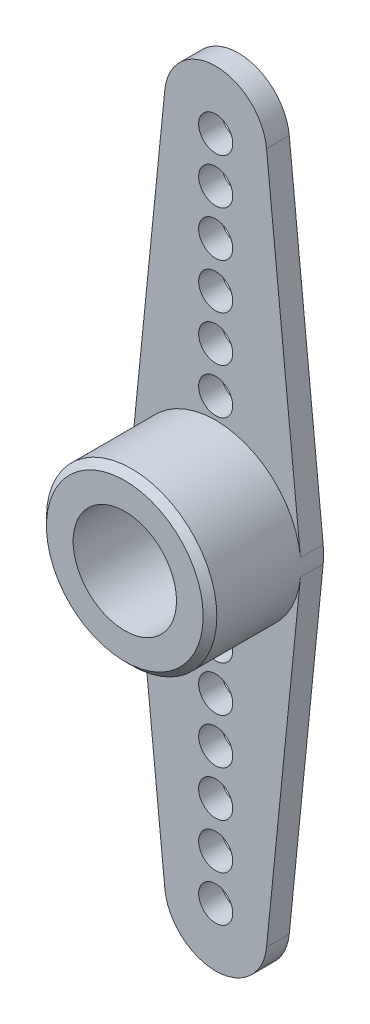
from build123d import *

# Parameters (mm, degrees)
BOSS_EXTRU_1_DEPTH      = 1
ESQUISSE2_R             = 3.75
BOSS_EXTRU_2_DEPTH      = 4
ESQUISSE3_R             = 2.275
ENL_V_MAT_EXTRU_1_DEPTH = 3.5
ESQUISSE4_R             = 2
ENL_V_MAT_EXTRU_2_DEPTH = 0.8
ESQUISSE5_R             = 0.75
ENL_V_MAT_EXTRU_3_DEPTH = 4.8
ESQUISSE6_R             = 0.75
ENL_V_MAT_EXTRU_4_DEPTH = 4.8
CHANFREIN1_SIZE         = 0.3
ESQUISSE7_W             = 9.343672426
ESQUISSE7_H             = 4.671442972
ENL_V_MAT_EXTRU_5_DEPTH = 10


with BuildPart() as part:
    # Esquisse1 → Boss.-Extru.1 (new body)
    with BuildSketch(Plane.XY):
        with BuildLine():
            Line((-2.238721733, 15.225), (-3.731202889, 0.375))
            ThreePointArc((-3.731202889, 0.375), (0, -3.75), (3.731202889, 0.375))
            Line((3.731202889, 0.375), (2.238721733, 15.225))
            ThreePointArc((2.238721733, 15.225), (0, 17.25), (-2.238721733, 15.225))
        make_face()
    extrude(amount=BOSS_EXTRU_1_DEPTH)

    # Esquisse2 → Boss.-Extru.2 (add)
    with BuildSketch(Plane.XY.offset(1)):
        with Locations(Location((0, 0, 0), (0, 0, 174.260829523))):
            Circle(ESQUISSE2_R)
    extrude(amount=BOSS_EXTRU_2_DEPTH)

    # Esquisse3 → Enlèv. mat.-Extru.1 (cut)
    with BuildSketch(Plane.XY.offset(5)):
        Circle(ESQUISSE3_R)
    extrude(amount=-ENL_V_MAT_EXTRU_1_DEPTH, mode=Mode.SUBTRACT)

    # Esquisse4 → Enlèv. mat.-Extru.2 (cut)
    with BuildSketch(Plane(origin=(0, 0, 0), x_dir=(-1, 0, 0), z_dir=(0, 0, -1))):
        Circle(ESQUISSE4_R)
    extrude(amount=-ENL_V_MAT_EXTRU_2_DEPTH, mode=Mode.SUBTRACT)

    # Esquisse5 → Enlèv. mat.-Extru.3 (cut)
    with BuildSketch(Plane(origin=(0, 0, 0.8), x_dir=(-1, 0, 0), z_dir=(0, 0, -1))):
        Circle(ESQUISSE5_R)
    extrude(amount=-ENL_V_MAT_EXTRU_3_DEPTH, mode=Mode.SUBTRACT)

    # Esquisse6 → Enlèv. mat.-Extru.4 (cut)
    with BuildSketch(Plane(origin=(0, 0, 0), x_dir=(-1, 0, 0), z_dir=(0, 0, -1))):
        with Locations((0, 4.672229454)):
            Circle(ESQUISSE6_R)
        with Locations((0, 6.672229454)):
            Circle(ESQUISSE6_R)
        with Locations((0, 8.672229454)):
            Circle(ESQUISSE6_R)
        with Locations((0, 10.672229454)):
            Circle(ESQUISSE6_R)
        with Locations((0, 12.672229454)):
            Circle(ESQUISSE6_R)
        with Locations((0, 14.672229454)):
            Circle(ESQUISSE6_R)
    extrude(amount=-ENL_V_MAT_EXTRU_4_DEPTH, mode=Mode.SUBTRACT)

    # Chanfrein1
    chanfrein1_edges = [part.edges().sort_by_distance(p)[0] for p in [
        (3.731202889, -0.375, 5),
    ]]
    chamfer(chanfrein1_edges, length=CHANFREIN1_SIZE)

    # Esquisse7 → Enlèv. mat.-Extru.5 (cut)
    with BuildSketch(Plane(origin=(0, 0, 0), x_dir=(-1, 0, 0), z_dir=(0, 0, -1))):
        with Locations((-0.484743233, -2.335721486)):
            Rectangle(ESQUISSE7_W, ESQUISSE7_H)
    extrude(amount=-ENL_V_MAT_EXTRU_5_DEPTH, mode=Mode.SUBTRACT)

    # Symétrie1: part across plane


with BuildPart() as part_1:
    add(part.part)
    add(part.part.mirror(Plane(origin=(5.156579446, 0, 10), x_dir=(0, 0, 1), z_dir=(0, 1, 0))))


solid = part_1.part
